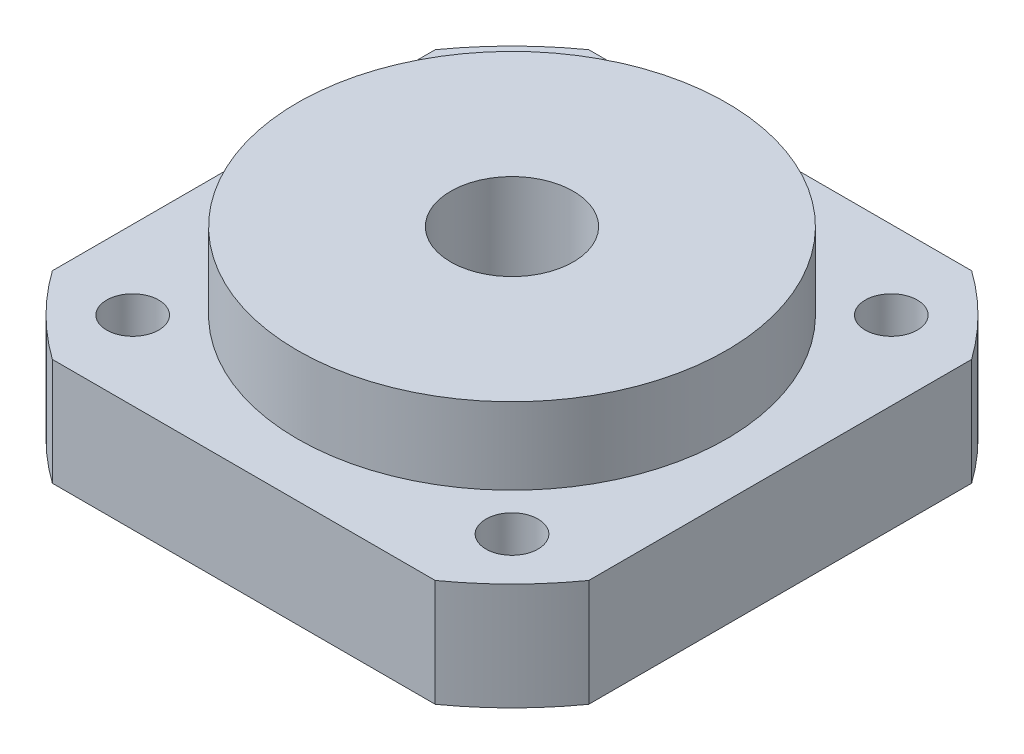
from build123d import *

# Parameters (mm, degrees)
SKETCH_5_R          = 4
SKETCH_5_R_2        = 1.7
EXTRUDE_2_DEPTH     = 12
SKETCH_7_W          = 35
SKETCH_7_H          = 35
SKETCH_7_R          = 14
CUT_EXTRUDE_4_DEPTH = 5
SKETCH_8_R          = 3.25
CUT_EXTRUDE_5_DEPTH = 4


with BuildPart() as part:
    # Эскиз5 → Бобышка-Вытянуть2 (new body)
    with BuildSketch(Plane(origin=(0, 0, 0), x_dir=(1, 0, 0), z_dir=(0, 1, 0))):
        with BuildLine():
            Line((-12.489995997, -17.5), (12.489995997, -17.5))
            ThreePointArc((12.489995997, -17.5), (15.202795796, -15.202795796), (17.5, -12.489995997))
            Line((17.5, -12.489995997), (17.5, 12.489995997))
            ThreePointArc((17.5, 12.489995997), (15.202795796, 15.202795796), (12.489995997, 17.5))
            Line((12.489995997, 17.5), (-12.489995997, 17.5))
            ThreePointArc((-12.489995997, 17.5), (-15.202795796, 15.202795796), (-17.5, 12.489995997))
            Line((-17.5, 12.489995997), (-17.5, -12.489995997))
            ThreePointArc((-17.5, -12.489995997), (-15.202795796, -15.202795796), (-12.489995997, -17.5))
        make_face()
        Circle(SKETCH_5_R, mode=Mode.SUBTRACT)
        with Locations((-12.374368671, 12.374368671)):
            Circle(SKETCH_5_R_2, mode=Mode.SUBTRACT)
        with Locations((12.374368671, 12.374368671)):
            Circle(SKETCH_5_R_2, mode=Mode.SUBTRACT)
        with Locations((12.374368671, -12.374368671)):
            Circle(SKETCH_5_R_2, mode=Mode.SUBTRACT)
        with Locations((-12.374368671, -12.374368671)):
            Circle(SKETCH_5_R_2, mode=Mode.SUBTRACT)
    extrude(amount=EXTRUDE_2_DEPTH)

    # Эскиз7 → Вырез-Вытянуть4 (cut)
    with BuildSketch(Plane(origin=(0, 12, 0), x_dir=(1, 0, 0), z_dir=(0, 1, 0))):
        Rectangle(SKETCH_7_W, SKETCH_7_H)
        Circle(SKETCH_7_R, mode=Mode.SUBTRACT)
    extrude(amount=-CUT_EXTRUDE_4_DEPTH, mode=Mode.SUBTRACT)

    # Эскиз8 → Вырез-Вытянуть5 (cut)
    with BuildSketch(Plane.XZ):
        with Locations((-12.374368671, 12.374368671)):
            Circle(SKETCH_8_R)
        with Locations((12.374368671, 12.374368671)):
            Circle(SKETCH_8_R)
        with Locations((12.374368671, -12.374368671)):
            Circle(SKETCH_8_R)
        with Locations((-12.374368671, -12.374368671)):
            Circle(SKETCH_8_R)
    extrude(amount=-CUT_EXTRUDE_5_DEPTH, mode=Mode.SUBTRACT)


solid = part.part
